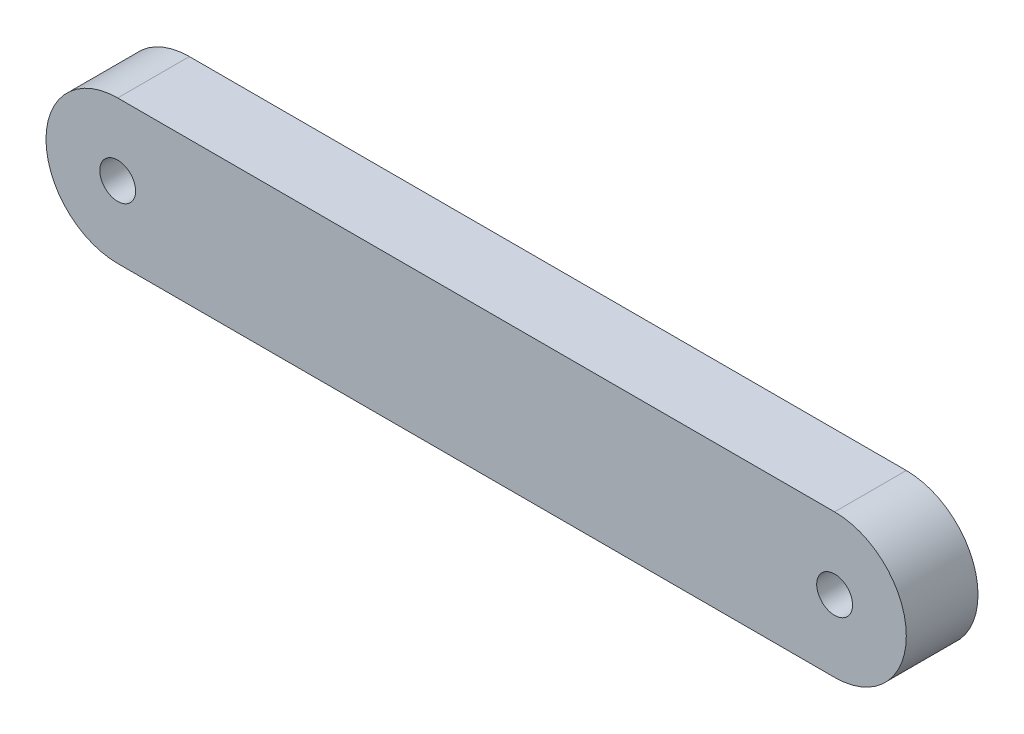
from build123d import *

# Parameters (mm, degrees)
BOSS_EXTRUDE1_DEPTH = 2.54
CUT_EXTRUDE1_START  = -3.54
SKETCH2_R           = 0.635
CUT_EXTRUDE1_DEPTH  = 4.54


with BuildPart() as part:
    # Sketch1 → Boss-Extrude1 (new body)
    with BuildSketch(Plane.XY):
        with BuildLine():
            Line((0, 2.54), (25.4, 2.54))
            ThreePointArc((25.4, 2.54), (27.94, 0), (25.4, -2.54))
            Line((25.4, -2.54), (0, -2.54))
            ThreePointArc((0, -2.54), (-2.54, 0), (0, 2.54))
        make_face()
    extrude(amount=BOSS_EXTRUDE1_DEPTH)

    # Sketch2 → Cut-Extrude1 (cut)
    with BuildSketch(Plane.XY.offset(2.54).offset(CUT_EXTRUDE1_START)):
        Circle(SKETCH2_R)
    cut_extrude1 = extrude(amount=CUT_EXTRUDE1_DEPTH, mode=Mode.SUBTRACT)

    # Mirror1: Cut-Extrude1 across plane
    add(cut_extrude1.mirror(Plane(origin=(12.7, 0, 0), x_dir=(0, 0, 1), z_dir=(1, 0, 0))), mode=Mode.SUBTRACT)


solid = part.part
